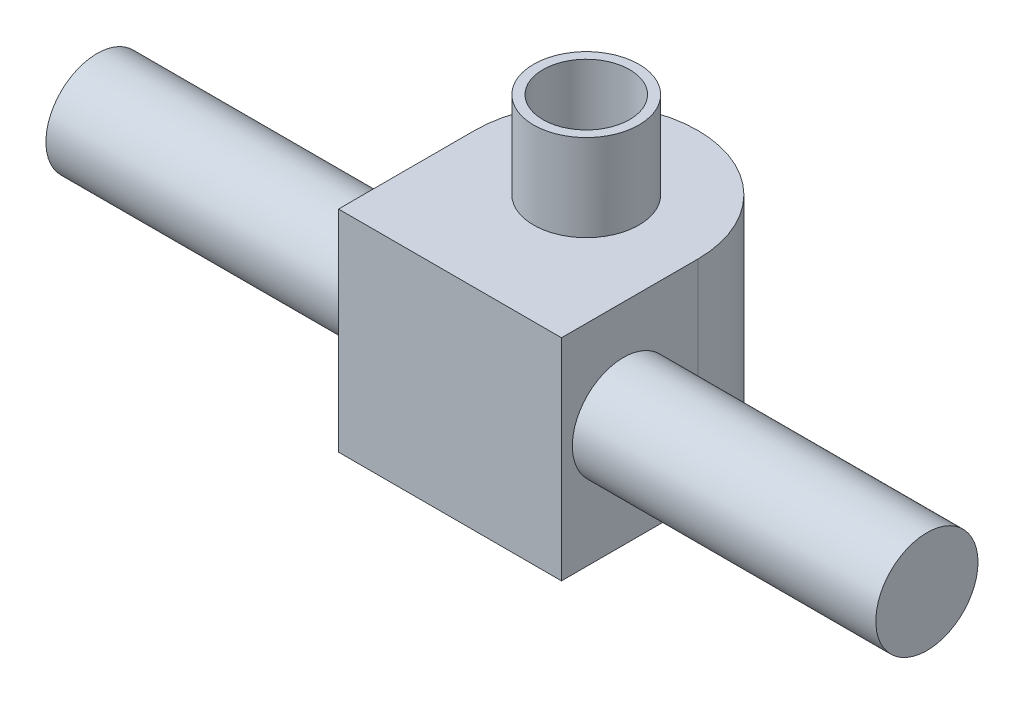
from build123d import *

# Parameters (mm, degrees)
SKETCH1_R                = 8.5
SKETCH1_R_2              = 7
BOSS_EXTRUDE1_DEPTH      = 48
SKETCH2_R                = 8.5
BOSS_EXTRUDE2_DEPTH      = 34
SKETCH3_R                = 1.5
CUT_EXTRUDE1_DEPTH       = 10
SKETCH4_R                = 8.25
BOSS_EXTRUDE3_DEPTH      = 67
BOSS_EXTRUDE3_DEPTH_BACK = 67


with BuildPart() as part:
    # Sketch1 → Boss-Extrude1 (new body)
    with BuildSketch(Plane(origin=(0, 0, 0), x_dir=(1, 0, 0), z_dir=(0, 1, 0))):
        Circle(SKETCH1_R)
        Circle(SKETCH1_R_2, mode=Mode.SUBTRACT)
    extrude(amount=BOSS_EXTRUDE1_DEPTH)

    # Sketch2 → Boss-Extrude2 (add)
    with BuildSketch(Plane.XZ):
        with BuildLine():
            Line((-18, 22), (18, 22))
            Line((18, 22), (18, 0))
            ThreePointArc((18, 0), (0, -18), (-18, 0))
            Line((-18, 0), (-18, 22))
        make_face()
        Circle(SKETCH2_R, mode=Mode.SUBTRACT)
    extrude(amount=-BOSS_EXTRUDE2_DEPTH)

    # Sketch3 → Cut-Extrude1 (cut)
    with BuildSketch(Plane.XZ):
        with Locations((0, -15.5)):
            Circle(SKETCH3_R)
        with Locations((-15.5, 0)):
            Circle(SKETCH3_R)
        with Locations((0, 15.5)):
            Circle(SKETCH3_R)
        with Locations((15.5, 0)):
            Circle(SKETCH3_R)
    extrude(amount=-CUT_EXTRUDE1_DEPTH, mode=Mode.SUBTRACT)

    # Sketch4 → Boss-Extrude3 (add, two sides)
    with BuildSketch(Plane(origin=(0, 0, 0), x_dir=(0, 0, -1), z_dir=(1, 0, 0))) as boss_extrude3_sk:
        with Locations((-12, 18)):
            Circle(SKETCH4_R)
    extrude(amount=BOSS_EXTRUDE3_DEPTH)
    extrude(boss_extrude3_sk.sketch, amount=-BOSS_EXTRUDE3_DEPTH_BACK)


solid = part.part
